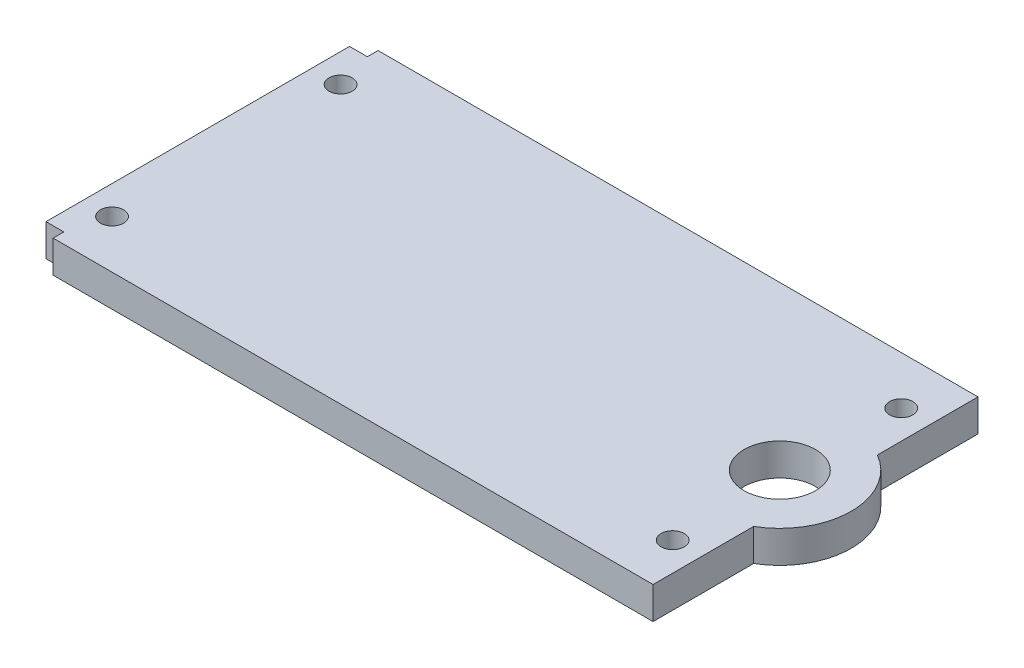
from build123d import *

# Parameters (mm, degrees)
SKETCH2_W           = 86.5
SKETCH2_H           = 45.5
BOSS_EXTRUDE1_DEPTH = 4.5
SKETCH3_R           = 1.625
CUT_EXTRUDE1_DEPTH  = 5.5
SKETCH5_R           = 10
BOSS_EXTRUDE2_DEPTH = 4.5
SKETCH6_R           = 5
CUT_EXTRUDE3_DEPTH  = 5.5
SKETCH7_W           = 2.5
SKETCH7_H           = 1.5
CUT_EXTRUDE4_DEPTH  = 5.5


with BuildPart() as part:
    # Sketch2 → Boss-Extrude1 (new body)
    with BuildSketch(Plane(origin=(0, 0, 0), x_dir=(1, 0, 0), z_dir=(0, 1, 0))):
        with Locations((1.75, 0)):
            Rectangle(SKETCH2_W, SKETCH2_H)
    extrude(amount=BOSS_EXTRUDE1_DEPTH)

    # Sketch3 → Cut-Extrude1 (cut, through all)
    with BuildSketch(Plane(origin=(0, 4.5, 0), x_dir=(1, 0, 0), z_dir=(0, 1, 0))):
        with Locations((-37.5, -16)):
            Circle(SKETCH3_R)
        with Locations((-37.5, 16)):
            Circle(SKETCH3_R)
        with Locations((41, 16)):
            Circle(SKETCH3_R)
        with Locations((41, -16)):
            Circle(SKETCH3_R)
    extrude(amount=-CUT_EXTRUDE1_DEPTH, mode=Mode.SUBTRACT)

    # Sketch5 → Boss-Extrude2 (add)
    with BuildSketch(Plane(origin=(0, 4.5, 0), x_dir=(1, 0, 0), z_dir=(0, 1, 0))):
        with Locations((40, 0)):
            Circle(SKETCH5_R)
    extrude(amount=-BOSS_EXTRUDE2_DEPTH)

    # Sketch6 → Cut-Extrude3 (cut, through all)
    with BuildSketch(Plane(origin=(0, 4.5, 0), x_dir=(1, 0, 0), z_dir=(0, 1, 0))):
        with Locations((40, 0)):
            Circle(SKETCH6_R)
    extrude(amount=-CUT_EXTRUDE3_DEPTH, mode=Mode.SUBTRACT)

    # Sketch7 → Cut-Extrude4 (cut, through all)
    with BuildSketch(Plane(origin=(0, 4.5, 0), x_dir=(1, 0, 0), z_dir=(0, 1, 0))):
        with Locations((-40.25, 22)):
            Rectangle(SKETCH7_W, SKETCH7_H)
        with Locations((-40.25, -22)):
            Rectangle(SKETCH7_W, SKETCH7_H)
    extrude(amount=-CUT_EXTRUDE4_DEPTH, mode=Mode.SUBTRACT)


solid = part.part
